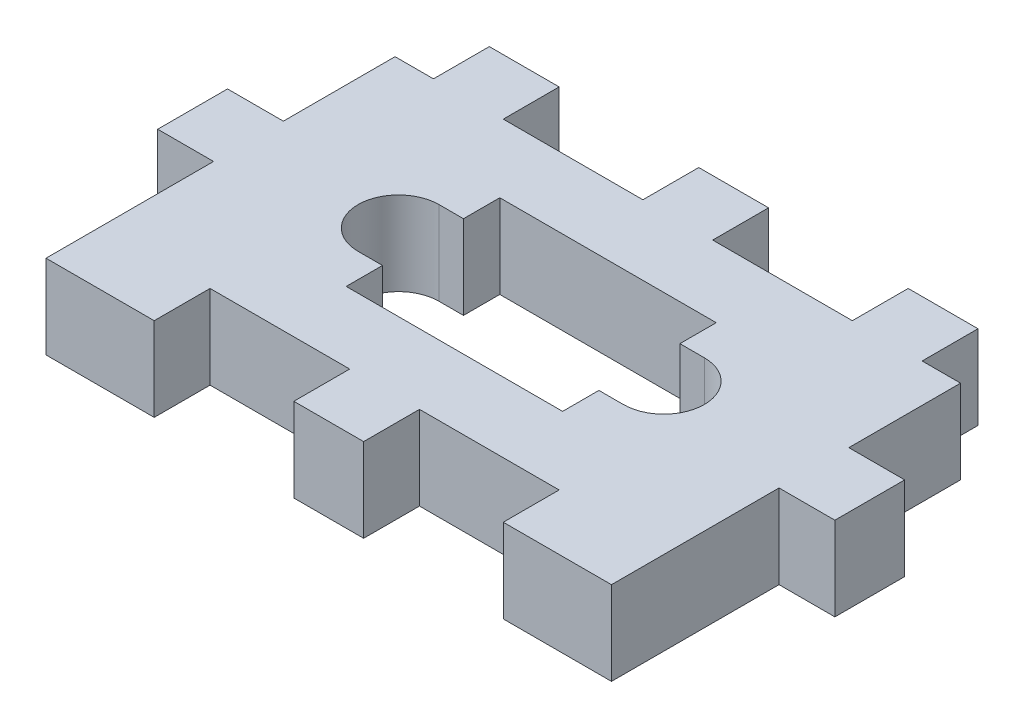
from build123d import *

# Parameters (mm, degrees)
SKETCH1_W           = 15.5
SKETCH1_H           = 11
BOSS_EXTRUDE1_DEPTH = 1.6
BOSS_EXTRUDE2_DEPTH = 1.6
SKETCH3_W           = 40.5
SKETCH3_H           = 21
BOSS_EXTRUDE3_DEPTH = 6
CUT_EXTRUDE1_DEPTH  = 2.6
SKETCH5_W           = 5
SKETCH5_H           = 4
BOSS_EXTRUDE4_DEPTH = 6
LPATTERN1_COUNT     = 2
LPATTERN1_PITCH     = 15
LPATTERN1_COL_COUNT = 2
LPATTERN1_COL_PITCH = 15
SKETCH6_W           = 4
SKETCH6_H           = 5
BOSS_EXTRUDE5_DEPTH = 6
SKETCH7_W           = 2.75
SKETCH7_H           = 4
BOSS_EXTRUDE6_DEPTH = 6


with BuildPart() as part:
    # Sketch1 → Boss-Extrude1 (new body)
    with BuildSketch(Plane(origin=(0, 0, 0), x_dir=(1, 0, 0), z_dir=(0, 1, 0))):
        with Locations((7.75, -5.5)):
            Rectangle(SKETCH1_W, SKETCH1_H)
    extrude(amount=BOSS_EXTRUDE1_DEPTH)

    # Sketch2 → Boss-Extrude2 (add, through all)
    with BuildSketch(Plane(origin=(0, 1.6, 0), x_dir=(1, 0, 0), z_dir=(0, 1, 0))):
        with BuildLine():
            Line((-1.75, -4), (-1.75, -2.6))
            ThreePointArc((-1.75, -2.6), (-4.65, -5.5), (-1.75, -8.4))
            Line((-1.75, -8.4), (-1.75, -7))
            ThreePointArc((-1.75, -7), (-3.25, -5.5), (-1.75, -4))
        make_face()
        with BuildLine():
            ThreePointArc((0, -3.187533784), (-0.827002716, -2.750804479), (-1.75, -2.6))
            Line((-1.75, -2.6), (-1.75, -4))
            ThreePointArc((-1.75, -4), (-0.689339828, -4.439339828), (-0.25, -5.5))
            ThreePointArc((-0.25, -5.5), (-0.689339828, -6.560660172), (-1.75, -7))
            Line((-1.75, -7), (-1.75, -8.4))
            ThreePointArc((-1.75, -8.4), (-0.827002716, -8.249195521), (0, -7.812466216))
            Line((0, -7.812466216), (0, -3.187533784))
        make_face()
        with BuildLine():
            Line((0, -2.6), (-1.75, -2.6))
            ThreePointArc((-1.75, -2.6), (-0.827002716, -2.750804479), (0, -3.187533784))
            Line((0, -3.187533784), (0, -2.6))
        make_face()
        with BuildLine():
            ThreePointArc((0, -7.812466216), (-0.827002716, -8.249195521), (-1.75, -8.4))
            Line((-1.75, -8.4), (0, -8.4))
            Line((0, -8.4), (0, -7.812466216))
        make_face()
        with BuildLine():
            ThreePointArc((20.15, -5.5), (19.300609665, -3.449390335), (17.25, -2.6))
            Line((17.25, -2.6), (17.25, -4))
            ThreePointArc((17.25, -4), (18.310660172, -4.439339828), (18.75, -5.5))
            ThreePointArc((18.75, -5.5), (18.310660172, -6.560660172), (17.25, -7))
            Line((17.25, -7), (17.25, -8.4))
            ThreePointArc((17.25, -8.4), (19.300609665, -7.550609665), (20.15, -5.5))
        make_face()
        with BuildLine():
            Line((17.25, -4), (17.25, -2.6))
            ThreePointArc((17.25, -2.6), (16.327002716, -2.750804479), (15.5, -3.187533784))
            Line((15.5, -3.187533784), (15.5, -7.812466216))
            ThreePointArc((15.5, -7.812466216), (16.327002716, -8.249195521), (17.25, -8.4))
            Line((17.25, -8.4), (17.25, -7))
            ThreePointArc((17.25, -7), (15.75, -5.5), (17.25, -4))
        make_face()
        with BuildLine():
            Line((17.25, -2.6), (15.5, -2.6))
            Line((15.5, -2.6), (15.5, -3.187533784))
            ThreePointArc((15.5, -3.187533784), (16.327002716, -2.750804479), (17.25, -2.6))
        make_face()
        with BuildLine():
            Line((15.5, -7.812466216), (15.5, -8.4))
            Line((15.5, -8.4), (17.25, -8.4))
            ThreePointArc((17.25, -8.4), (16.327002716, -8.249195521), (15.5, -7.812466216))
        make_face()
    extrude(amount=-BOSS_EXTRUDE2_DEPTH)

    # Sketch4 → Cut-Extrude1 (cut, through all)
    with BuildSketch(Plane(origin=(0, 1.6, 0), x_dir=(1, 0, 0), z_dir=(0, 1, 0))):
        with BuildLine():
            Line((0, 0), (0, -2.6))
            Line((0, -2.6), (-1.75, -2.6))
            ThreePointArc((-1.75, -2.6), (-4.65, -5.5), (-1.75, -8.4))
            Line((-1.75, -8.4), (0, -8.4))
            Line((0, -8.4), (0, -11))
            Line((0, -11), (15.5, -11))
            Line((15.5, -11), (15.5, -8.4))
            Line((15.5, -8.4), (17.25, -8.4))
            ThreePointArc((17.25, -8.4), (20.15, -5.5), (17.25, -2.6))
            Line((17.25, -2.6), (15.5, -2.6))
            Line((15.5, -2.6), (15.5, 0))
            Line((15.5, 0), (0, 0))
        make_face()
    extrude(amount=-CUT_EXTRUDE1_DEPTH, mode=Mode.SUBTRACT)


with BuildPart() as body_2:
    # Sketch3 → Boss-Extrude3 (new body)
    with BuildSketch(Plane(origin=(0, 1.6, 0), x_dir=(1, 0, 0), z_dir=(0, 1, 0))):
        with Locations((7.75, -5.5)):
            Rectangle(SKETCH3_W, SKETCH3_H)
        with BuildLine():
            Line((0, 0), (0, -2.6))
            Line((0, -2.6), (-1.75, -2.6))
            ThreePointArc((-1.75, -2.6), (-4.65, -5.5), (-1.75, -8.4))
            Line((-1.75, -8.4), (0, -8.4))
            Line((0, -8.4), (0, -11))
            Line((0, -11), (15.5, -11))
            Line((15.5, -11), (15.5, -8.4))
            Line((15.5, -8.4), (17.25, -8.4))
            ThreePointArc((17.25, -8.4), (20.15, -5.5), (17.25, -2.6))
            Line((17.25, -2.6), (15.5, -2.6))
            Line((15.5, -2.6), (15.5, 0))
            Line((15.5, 0), (0, 0))
        make_face(mode=Mode.SUBTRACT)
    extrude(amount=BOSS_EXTRUDE3_DEPTH)

    # Sketch5 → Boss-Extrude4 (add, through all)
    with BuildSketch(Plane(origin=(0, 7.6, 0), x_dir=(1, 0, 0), z_dir=(0, 1, 0))):
        with Locations((7.75, 7)):
            Rectangle(SKETCH5_W, SKETCH5_H)
        with Locations((7.75, -18)):
            Rectangle(SKETCH5_W, SKETCH5_H)
    boss_extrude4 = extrude(amount=-BOSS_EXTRUDE4_DEPTH)

    # LPattern1: Boss-Extrude4 ×2
    with Locations(*[(i * LPATTERN1_PITCH, 0, 0) for i in range(1, LPATTERN1_COUNT)]):
        add(boss_extrude4)

    # LPattern1 col: Boss-Extrude4 ×2
    with Locations(*[(-i * LPATTERN1_COL_PITCH, 0, 0) for i in range(1, LPATTERN1_COL_COUNT)]):
        add(boss_extrude4)

    # Sketch6 → Boss-Extrude5 (add, through all)
    with BuildSketch(Plane(origin=(0, 7.6, 0), x_dir=(1, 0, 0), z_dir=(0, 1, 0))):
        with Locations((-14.5, -5.5)):
            Rectangle(SKETCH6_W, SKETCH6_H)
        with Locations((30, -5.5)):
            Rectangle(SKETCH6_W, SKETCH6_H)
    extrude(amount=-BOSS_EXTRUDE5_DEPTH)

    # Sketch7 → Boss-Extrude6 (add, through all)
    with BuildSketch(Plane(origin=(0, 1.6, 0), x_dir=(-1, 0, 0), z_dir=(0, -1, 0))):
        with Locations((11.125, -18)):
            Rectangle(SKETCH7_W, SKETCH7_H)
        with Locations((-26.625, -18)):
            Rectangle(SKETCH7_W, SKETCH7_H)
    extrude(amount=-BOSS_EXTRUDE6_DEPTH)


solid = body_2.part
